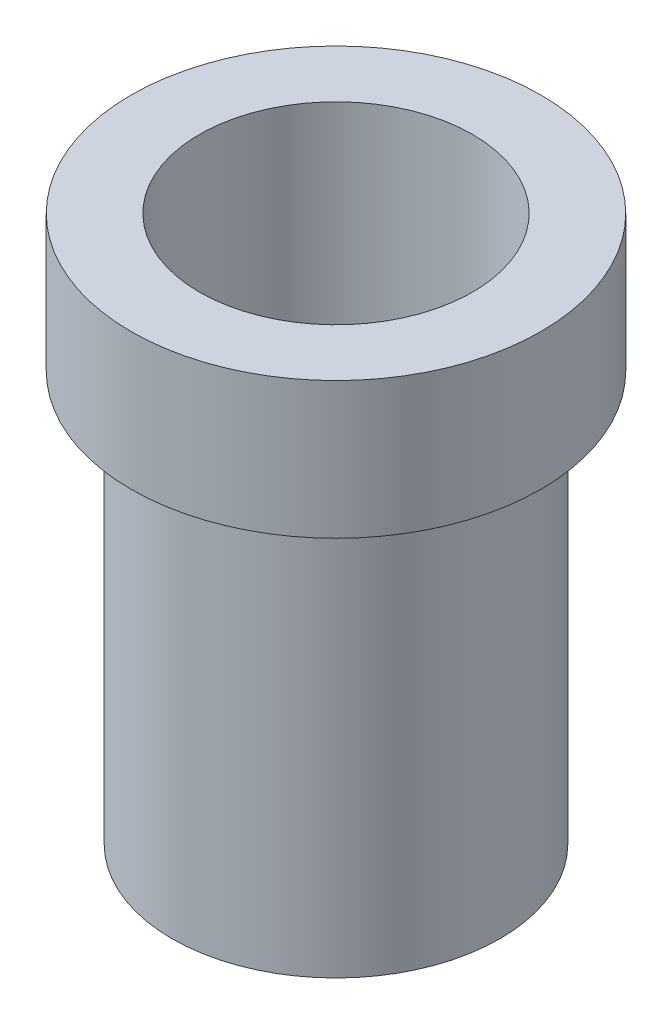
from build123d import *

# Parameters (mm, degrees)
ESQUISSE1_R      = 7.5
EXTRUSION1_DEPTH = 5
ESQUISSE2_R      = 6
EXTRUSION2_DEPTH = 15
EXTRUSION3_REACH = 22
ESQUISSE3_R      = 5


with BuildPart() as part:
    # Esquisse1 → Extrusion1 (new body)
    with BuildSketch(Plane(origin=(0, 0, 0), x_dir=(1, 0, 0), z_dir=(0, 1, 0))):
        Circle(ESQUISSE1_R)
    extrude(amount=EXTRUSION1_DEPTH)

    # Esquisse2 → Extrusion2 (add)
    with BuildSketch(Plane.XZ):
        Circle(ESQUISSE2_R)
    extrude(amount=EXTRUSION2_DEPTH)

    # Esquisse3 → Extrusion3 (cut, up to next)
    with BuildSketch(Plane(origin=(0, 5, 0), x_dir=(1, 0, 0), z_dir=(0, 1, 0)), mode=Mode.PRIVATE) as extrusion3_sk1:
        Circle(ESQUISSE3_R)
    extrusion3_tool1 = extrude(extrusion3_sk1.sketch, amount=-EXTRUSION3_REACH, mode=Mode.PRIVATE) & part.part
    add(extrusion3_tool1.solids().sort_by_distance((0, 5, 0))[0], mode=Mode.SUBTRACT)


solid = part.part
